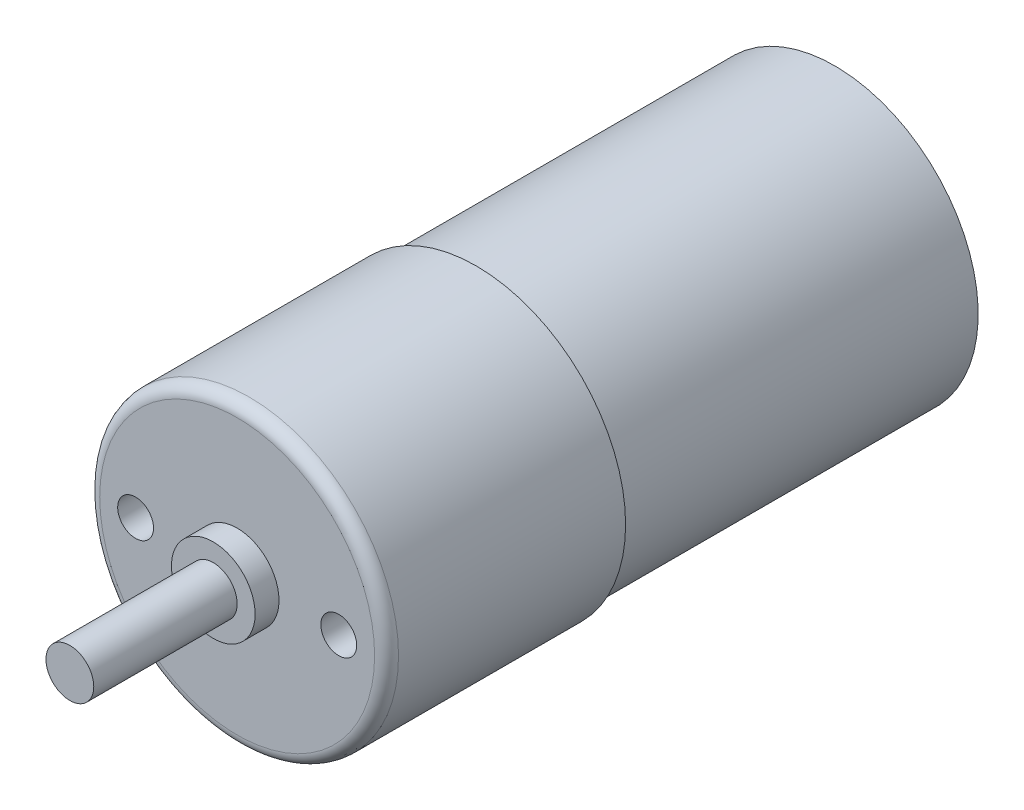
from build123d import *

# Parameters (mm, degrees)
SKETCH1_R           = 12.5
BOSS_EXTRUDE1_DEPTH = 50
SKETCH2_R           = 3.5
BOSS_EXTRUDE2_DEPTH = 2
SKETCH3_R           = 2
BOSS_EXTRUDE3_DEPTH = 12
SKETCH4_R           = 12.5
SKETCH4_R_2         = 12
CUT_EXTRUDE1_DEPTH  = 30
FILLET1_R           = 1
SKETCH5_R           = 3.070760983
BOSS_EXTRUDE4_DEPTH = 1
FILLET2_R           = 0.5
SKETCH6_R           = 1.5
CUT_EXTRUDE2_DEPTH  = 10


with BuildPart() as part:
    # Sketch1 → Boss-Extrude1 (new body)
    with BuildSketch(Plane.XY):
        Circle(SKETCH1_R)
    extrude(amount=BOSS_EXTRUDE1_DEPTH)

    # Sketch2 → Boss-Extrude2 (add)
    with BuildSketch(Plane.XY.offset(50)):
        Circle(SKETCH2_R)
    extrude(amount=BOSS_EXTRUDE2_DEPTH)

    # Sketch3 → Boss-Extrude3 (add)
    with BuildSketch(Plane.XY.offset(52)):
        Circle(SKETCH3_R)
    extrude(amount=BOSS_EXTRUDE3_DEPTH)

    # Sketch4 → Cut-Extrude1 (cut)
    with BuildSketch(Plane(origin=(0, 0, 0), x_dir=(-1, 0, 0), z_dir=(0, 0, -1))):
        Circle(SKETCH4_R)
        Circle(SKETCH4_R_2, mode=Mode.SUBTRACT)
    extrude(amount=-CUT_EXTRUDE1_DEPTH, mode=Mode.SUBTRACT)

    # Fillet1
    fillet1_edges = [part.edges().sort_by_distance(p)[0] for p in [
        (-12.5, 0, 50),
    ]]
    fillet(fillet1_edges, radius=FILLET1_R)

    # Sketch5 → Boss-Extrude4 (add)
    with BuildSketch(Plane(origin=(0, 0, 0), x_dir=(-1, 0, 0), z_dir=(0, 0, -1))):
        Circle(SKETCH5_R)
    extrude(amount=BOSS_EXTRUDE4_DEPTH)

    # Fillet2
    fillet2_edges = [part.edges().sort_by_distance(p)[0] for p in [
        (3.070760983, 0, -1),
    ]]
    fillet(fillet2_edges, radius=FILLET2_R)

    # Sketch6 → Cut-Extrude2 (cut)
    with BuildSketch(Plane.XY.offset(50)):
        with Locations((8.5, 0)):
            Circle(SKETCH6_R)
        with Locations((-8.5, 0)):
            Circle(SKETCH6_R)
    extrude(amount=-CUT_EXTRUDE2_DEPTH, mode=Mode.SUBTRACT)


solid = part.part
